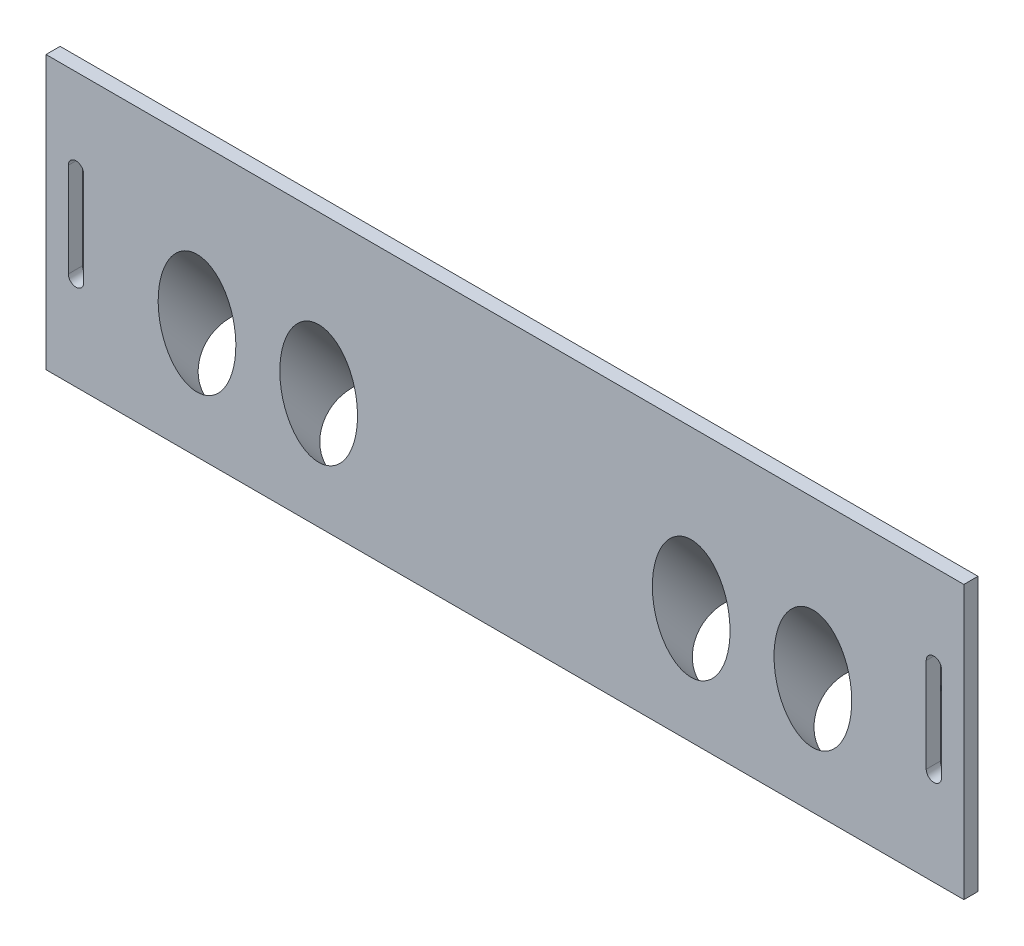
from build123d import *

# Parameters (mm, degrees)
CROQUIS1_W              = 195
CROQUIS1_H              = 38
CROQUIS1_R              = 1.625
SALIENTE_EXTRUIR1_DEPTH = 3
SALIENTE_EXTRUIR2_START = -67.5
SALIENTE_EXTRUIR2_DEPTH = 45
SALIENTE_EXTRUIR3_START = -67.5
SALIENTE_EXTRUIR3_DEPTH = 45
CROQUIS8_W              = 195
CROQUIS8_H              = 3
SALIENTE_EXTRUIR5_DEPTH = 5
CROQUIS9_R              = 8.25
CORTAR_EXTRUIR4_DEPTH   = 106.640382748
CROQUIS10_W             = 195
CROQUIS10_H             = 3
SALIENTE_EXTRUIR6_DEPTH = 15
CORTAR_EXTRUIR5_DEPTH   = 15


with BuildPart() as part:
    # Croquis1 → Saliente-Extruir1 (new body)
    with BuildSketch(Plane.XY):
        with Locations((0, 19)):
            Rectangle(CROQUIS1_W, CROQUIS1_H)
        with Locations((91.125, 15)):
            Circle(CROQUIS1_R, mode=Mode.SUBTRACT)
        with Locations(Location((-91.125, 15, 0), (0, 0, 180))):
            Circle(CROQUIS1_R, mode=Mode.SUBTRACT)
    extrude(amount=SALIENTE_EXTRUIR1_DEPTH)

    # Croquis2 → Saliente-Extruir2 (add)
    with BuildSketch(Plane(origin=(97.5, 0, 0), x_dir=(0, 0, -1), z_dir=(1, 0, 0)).offset(SALIENTE_EXTRUIR2_START)):
        Polygon((0, 0.738403157), (3.429565646, 3.677896428), (15.185426147, 13.753887502), (0, 31.471028189), align=None)
    extrude(amount=SALIENTE_EXTRUIR2_DEPTH)

    # Croquis4 → Saliente-Extruir3 (add)
    with BuildSketch(Plane.ZY.offset(97.5).offset(SALIENTE_EXTRUIR3_START)):
        Polygon((0, 0.738403157), (-15.185426147, 13.753887502), (0, 31.471028189), align=None)
    extrude(amount=SALIENTE_EXTRUIR3_DEPTH)

    # Croquis8 → Saliente-Extruir5 (add)
    with BuildSketch(Plane.XZ):
        with Locations((0, 1.5)):
            Rectangle(CROQUIS8_W, CROQUIS8_H)
    extrude(amount=SALIENTE_EXTRUIR5_DEPTH)

    # Croquis9 → Cortar-Extruir4 (cut, through all)
    with BuildSketch(Plane(origin=(0, 0.425684191, 0.364855478), x_dir=(1, 0, 0), z_dir=(0, -0.7592713073348798, -0.6507742172658522))):
        with Locations(Location((-65.42, -10.480533736, 0), (0, 0, 270))):
            Circle(CROQUIS9_R)
        with Locations(Location((-39.57, -10.480533736, 0), (0, 0, 270))):
            Circle(CROQUIS9_R)
        with Locations(Location((39.57, -10.480533736, 0), (0, 0, 90))):
            Circle(CROQUIS9_R)
        with Locations(Location((65.42, -10.480533736, 0), (0, 0, 90))):
            Circle(CROQUIS9_R)
    extrude(amount=-CORTAR_EXTRUIR4_DEPTH, mode=Mode.SUBTRACT)

    # Croquis10 → Saliente-Extruir6 (add)
    with BuildSketch(Plane(origin=(0, 38, 0), x_dir=(1, 0, 0), z_dir=(0, 1, 0))):
        with Locations((0, -1.5)):
            Rectangle(CROQUIS10_W, CROQUIS10_H)
    extrude(amount=SALIENTE_EXTRUIR6_DEPTH)

    # Croquis11 → Cortar-Extruir5 (cut)
    with BuildSketch(Plane(origin=(0, 0, 0), x_dir=(-1, 0, 0), z_dir=(0, 0, -1))):
        with BuildLine():
            Line((-92.75, 15), (-92.75, 35))
            ThreePointArc((-92.75, 35), (-91.125, 36.625), (-89.5, 35))
            Line((-89.5, 35), (-89.5, 15))
            ThreePointArc((-89.5, 15), (-91.125, 13.375), (-92.75, 15))
        make_face()
        with BuildLine():
            Line((89.5, 35), (89.5, 15))
            ThreePointArc((89.5, 15), (91.125, 13.375), (92.75, 15))
            Line((92.75, 15), (92.75, 35))
            ThreePointArc((92.75, 35), (91.125, 36.625), (89.5, 35))
        make_face()
    extrude(amount=-CORTAR_EXTRUIR5_DEPTH, mode=Mode.SUBTRACT)


solid = part.part
